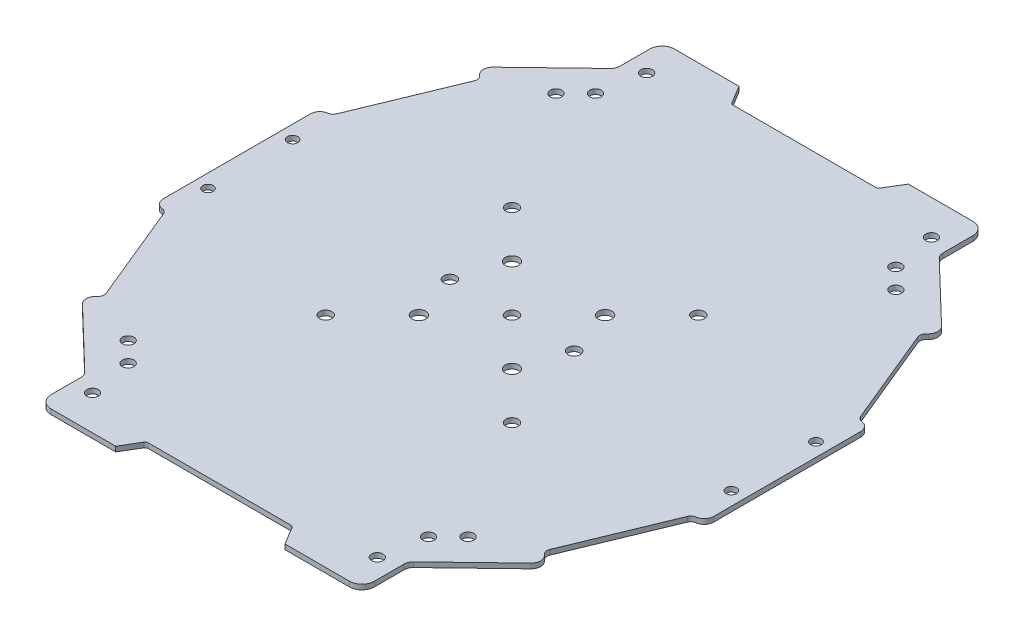
from build123d import *

# Parameters (mm, degrees)
SKETCH1_R        = 2.2
SKETCH1_R_2      = 1.85915493
SKETCH1_R_3      = 2
SKETCH1_R_4      = 1.673239437
SKETCH1_R_5      = 1.983111479
EXTRUSION1_DEPTH = 1.6
FILLET1_R        = 1
FILLET2_R        = 4
FILLET3_R        = 3
FILLET4_R        = 3
FILLET5_R        = 2
FILLET6_R        = 2
FILLET7_R        = 3
FILLET8_R        = 3
FILLET9_R        = 2
FILLET10_R       = 2
FILLET11_R       = 3


with BuildPart() as part:
    # Sketch1 → Extrusion1 (new body)
    with BuildSketch(Plane(origin=(0, 0, 0), x_dir=(-1, 0, 0), z_dir=(0, 1, 0))):
        Polygon((74.087520418, 321.088295015), (70.369210559, 327.285477572), (45.580478165, 327.285477572), (45.580478165, 312.412238135), (23.246043749, 290.934342561), (26.682507041, 287.360833055), (12.735407819, 253.538985229), (9.017097883, 253.538985229), (9.017097883, 226.891111382), (9.017097883, 200.243237534), (12.735407819, 200.243237534), (26.682507041, 166.421389708), (23.246043749, 162.847880202), (45.580478165, 141.369984628), (45.580478165, 126.496745191), (70.369210559, 126.496745191), (74.087520418, 132.693927748), (97.636816193, 132.693927748), (121.186111968, 132.693927748), (124.904421827, 126.496745191), (149.693154221, 126.496745191), (149.693154221, 141.369984628), (172.027588636, 162.847880202), (168.591125345, 166.421389708), (182.538224567, 200.243237534), (186.256534503, 200.243237534), (186.256534503, 226.891111382), (186.256534503, 253.538985229), (182.538224567, 253.538985229), (168.591125345, 287.360833055), (172.027588636, 290.934342561), (149.693154221, 312.412238135), (149.693154221, 327.285477572), (124.904421827, 327.285477572), (121.186111968, 321.088295015), (97.636816193, 321.088295015), align=None)
        with Locations((112.636816193, 211.891111382)):
            Circle(SKETCH1_R, mode=Mode.SUBTRACT)
        with Locations((49.266182018, 151.62213525)):
            Circle(SKETCH1_R_2, mode=Mode.SUBTRACT)
        with Locations((112.636816193, 241.891111382)):
            Circle(SKETCH1_R, mode=Mode.SUBTRACT)
        with Locations((82.636816193, 241.891111382)):
            Circle(SKETCH1_R, mode=Mode.SUBTRACT)
        with Locations((82.636816193, 211.891111382)):
            Circle(SKETCH1_R, mode=Mode.SUBTRACT)
        with Locations((117.636816193, 226.891111382)):
            Circle(SKETCH1_R_3, mode=Mode.SUBTRACT)
        with Locations((77.636816193, 226.891111382)):
            Circle(SKETCH1_R_3, mode=Mode.SUBTRACT)
        with Locations((97.636816193, 226.891111382)):
            Circle(SKETCH1_R_3, mode=Mode.SUBTRACT)
        with Locations((51.777661187, 316.130534525)):
            Circle(SKETCH1_R_2, mode=Mode.SUBTRACT)
        with Locations((49.266182018, 302.160087513)):
            Circle(SKETCH1_R_2, mode=Mode.SUBTRACT)
        with Locations((13.355125975, 240.524915841)):
            Circle(SKETCH1_R_4, mode=Mode.SUBTRACT)
        with Locations((143.495971199, 137.651688238)):
            Circle(SKETCH1_R_2, mode=Mode.SUBTRACT)
        with Locations((146.007450368, 151.62213525)):
            Circle(SKETCH1_R_2, mode=Mode.SUBTRACT)
        with Locations((143.495971199, 316.130534525)):
            Circle(SKETCH1_R_2, mode=Mode.SUBTRACT)
        with Locations((181.918506411, 240.524915841)):
            Circle(SKETCH1_R_4, mode=Mode.SUBTRACT)
        with Locations((146.007450368, 302.160087513)):
            Circle(SKETCH1_R_2, mode=Mode.SUBTRACT)
        with Locations((181.918506411, 213.257306923)):
            Circle(SKETCH1_R_4, mode=Mode.SUBTRACT)
        with Locations((13.355125975, 213.257306923)):
            Circle(SKETCH1_R_4, mode=Mode.SUBTRACT)
        with Locations((51.777661187, 137.651688238)):
            Circle(SKETCH1_R_2, mode=Mode.SUBTRACT)
        with Locations((67.636816193, 196.891111382)):
            Circle(SKETCH1_R_5, mode=Mode.SUBTRACT)
        with Locations((67.636816193, 256.891111382)):
            Circle(SKETCH1_R_5, mode=Mode.SUBTRACT)
        with Locations((42.888078851, 158.000238416)):
            Circle(SKETCH1_R_2, mode=Mode.SUBTRACT)
        with Locations((152.385553534, 295.781984347)):
            Circle(SKETCH1_R_2, mode=Mode.SUBTRACT)
        with Locations((42.888078851, 295.781984347)):
            Circle(SKETCH1_R_2, mode=Mode.SUBTRACT)
        with Locations((127.636816193, 256.891111382)):
            Circle(SKETCH1_R_5, mode=Mode.SUBTRACT)
        with Locations((152.385553534, 158.000238416)):
            Circle(SKETCH1_R_2, mode=Mode.SUBTRACT)
        with Locations((127.636816193, 196.891111382)):
            Circle(SKETCH1_R_5, mode=Mode.SUBTRACT)
    extrude(amount=EXTRUSION1_DEPTH)

    # Fillet1
    fillet1_edges = [part.edges().sort_by_distance(p)[0] for p in [
        (-121.186111968, 0.8, 321.088295015),
        (-121.186111968, 0.8, 132.693927748),
        (-74.087520418, 0.8, 132.693927748),
        (-74.087520418, 0.8, 321.088295015),
    ]]
    fillet(fillet1_edges, radius=FILLET1_R)

    # Fillet2
    fillet2_edges = [part.edges().sort_by_distance(p)[0] for p in [
        (-149.693154221, 0.8, 327.285477572),
        (-149.693154221, 0.8, 126.496745191),
        (-45.580478165, 0.8, 126.496745191),
        (-45.580478165, 0.8, 327.285477572),
    ]]
    fillet(fillet2_edges, radius=FILLET2_R)

    # Fillet3
    fillet3_edges = [part.edges().sort_by_distance(p)[0] for p in [
        (-149.693154221, 0.8, 312.412238135),
        (-149.693154221, 0.8, 141.369984628),
        (-45.580478165, 0.8, 141.369984628),
        (-45.580478165, 0.8, 312.412238135),
    ]]
    fillet(fillet3_edges, radius=FILLET3_R)

    # Fillet4
    fillet4_edges = [part.edges().sort_by_distance(p)[0] for p in [
        (-172.027588636, 0.8, 290.934342561),
    ]]
    fillet(fillet4_edges, radius=FILLET4_R)

    # Fillet5
    fillet5_edges = [part.edges().sort_by_distance(p)[0] for p in [
        (-168.591125345, 0.8, 287.360833055),
    ]]
    fillet(fillet5_edges, radius=FILLET5_R)

    # Fillet6
    fillet6_edges = [part.edges().sort_by_distance(p)[0] for p in [
        (-26.682507041, 0.8, 287.360833055),
    ]]
    fillet(fillet6_edges, radius=FILLET6_R)

    # Fillet7
    fillet7_edges = [part.edges().sort_by_distance(p)[0] for p in [
        (-23.246043749, 0.8, 290.934342561),
    ]]
    fillet(fillet7_edges, radius=FILLET7_R)

    # Fillet8
    fillet8_edges = [part.edges().sort_by_distance(p)[0] for p in [
        (-172.027588636, 0.8, 162.847880202),
        (-23.246043749, 0.8, 162.847880202),
    ]]
    fillet(fillet8_edges, radius=FILLET8_R)

    # Fillet9
    fillet9_edges = [part.edges().sort_by_distance(p)[0] for p in [
        (-168.591125345, 0.8, 166.421389708),
        (-26.682507041, 0.8, 166.421389708),
    ]]
    fillet(fillet9_edges, radius=FILLET9_R)

    # Fillet10
    fillet10_edges = [part.edges().sort_by_distance(p)[0] for p in [
        (-182.538224567, 0.8, 253.538985229),
        (-182.538224567, 0.8, 200.243237534),
        (-12.735407819, 0.8, 200.243237534),
        (-12.735407819, 0.8, 253.538985229),
    ]]
    fillet(fillet10_edges, radius=FILLET10_R)

    # Fillet11
    fillet11_edges = [part.edges().sort_by_distance(p)[0] for p in [
        (-186.256534503, 0.8, 200.243237534),
        (-186.256534503, 0.8, 253.538985229),
        (-9.017097883, 0.8, 253.538985229),
        (-9.017097883, 0.8, 200.243237534),
    ]]
    fillet(fillet11_edges, radius=FILLET11_R)


solid = part.part
